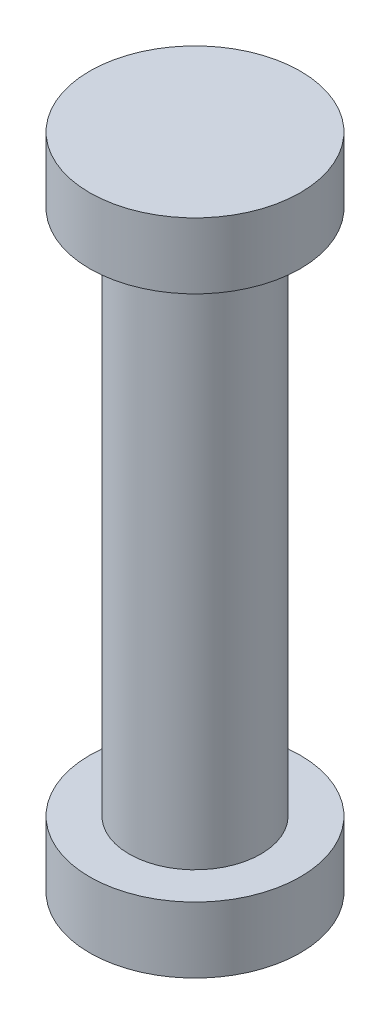
from build123d import *

# Parameters (mm, degrees)
SZKIC1_R                    = 5
DODANIE_WYCI_GNI_CIE1_DEPTH = 40
SZKIC3_R                    = 8
DODANIE_WYCI_GNI_CIE2_DEPTH = 5
SZKIC2_R                    = 8
DODANIE_WYCI_GNI_CIE3_DEPTH = 5


with BuildPart() as part:
    # Szkic1 → Dodanie-wyciągnięcie1 (new body)
    with BuildSketch(Plane(origin=(0, 0, 0), x_dir=(1, 0, 0), z_dir=(0, 1, 0))):
        Circle(SZKIC1_R)
    extrude(amount=DODANIE_WYCI_GNI_CIE1_DEPTH)

    # Szkic3 → Dodanie-wyciągnięcie2 (add)
    with BuildSketch(Plane.XZ):
        Circle(SZKIC3_R)
    extrude(amount=DODANIE_WYCI_GNI_CIE2_DEPTH)

    # Szkic2 → Dodanie-wyciągnięcie3 (add)
    with BuildSketch(Plane(origin=(0, 40, 0), x_dir=(1, 0, 0), z_dir=(0, 1, 0))):
        Circle(SZKIC2_R)
    extrude(amount=DODANIE_WYCI_GNI_CIE3_DEPTH)


solid = part.part
